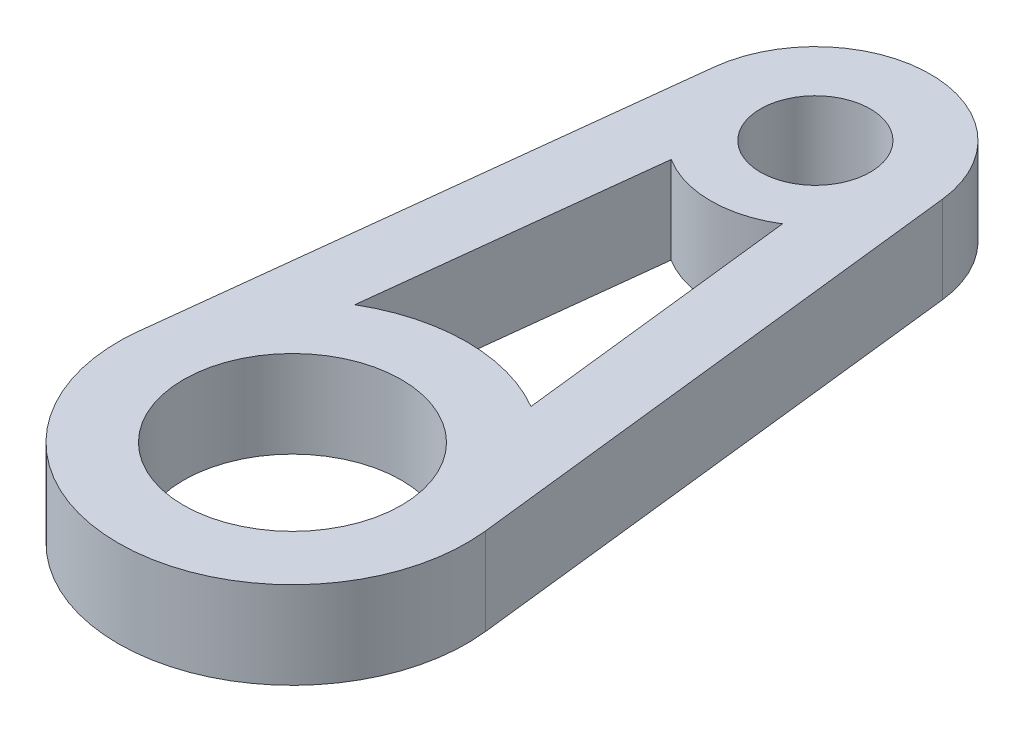
from build123d import *

# Parameters (mm, degrees)
SKETCH2_R           = 2
SKETCH2_R_2         = 3.96875
BOSS_EXTRUDE1_DEPTH = 3.175


with BuildPart() as part:
    # Sketch2 → Boss-Extrude1 (new body)
    with BuildSketch(Plane(origin=(0, 0, 0), x_dir=(1, 0, 0), z_dir=(0, 1, 0))):
        with BuildLine():
            Line((4.163997478, 0.47498), (6.309087088, -18.330333333))
            ThreePointArc((6.309087088, -18.330333333), (0, -25.4), (-6.309087088, -18.330333333))
            Line((-6.309087088, -18.330333333), (-4.163997478, 0.47498))
            ThreePointArc((-4.163997478, 0.47498), (0, 4.191), (4.163997478, 0.47498))
        make_face()
        Circle(SKETCH2_R, mode=Mode.SUBTRACT)
        with Locations((0, -19.05)):
            Circle(SKETCH2_R_2, mode=Mode.SUBTRACT)
        with BuildLine():
            Line((3.20971892, -13.570930329), (2.029515364, -3.224463891))
            ThreePointArc((2.029515364, -3.224463891), (0, -3.81), (-2.029515364, -3.224463891))
            Line((-2.029515364, -3.224463891), (-3.20971892, -13.570930329))
            ThreePointArc((-3.20971892, -13.570930329), (0, -12.7), (3.20971892, -13.570930329))
        make_face(mode=Mode.SUBTRACT)
    extrude(amount=BOSS_EXTRUDE1_DEPTH)


solid = part.part
